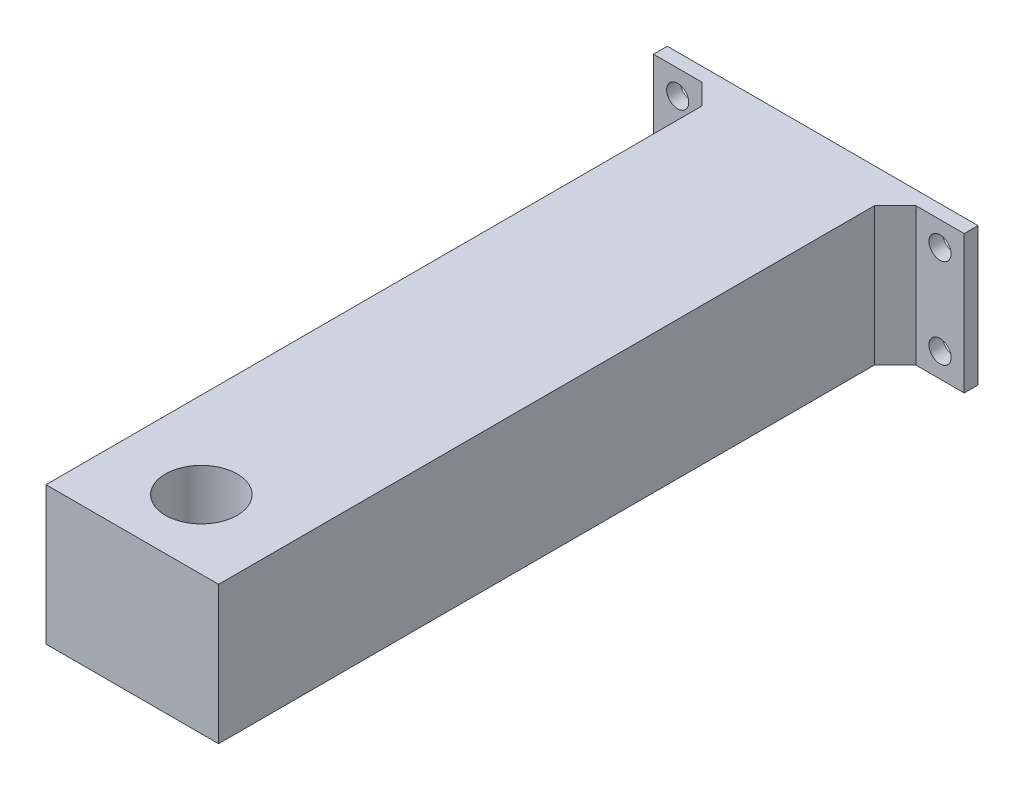
from build123d import *

# Parameters (mm, degrees)
SKETCH_1_W          = 25
SKETCH_1_H          = 20
EXTRUDE_1_DEPTH     = 100
SKETCH_2_R          = 5.2
CUT_EXTRUDE_1_DEPTH = 8
SKETCH_3_W          = 2
SKETCH_3_H          = 20
EXTRUDE_2_DEPTH     = 10
EXTRUDE_3_DEPTH     = 20
SKETCH_6_R          = 1.6
CUT_EXTRUDE_2_DEPTH = 3
SKETCH_7_W          = 2
SKETCH_7_H          = 20
EXTRUDE_4_DEPTH     = 10
EXTRUDE_5_DEPTH     = 20
SKETCH_9_R          = 1.6
CUT_EXTRUDE_3_DEPTH = 3


with BuildPart() as part:
    # ｽｹｯﾁ1 → ﾎﾞｽ - 押し出し1 (new body)
    with BuildSketch(Plane.XY):
        with Locations((-0.22894462, -4.808467742)):
            Rectangle(SKETCH_1_W, SKETCH_1_H)
    extrude(amount=EXTRUDE_1_DEPTH)

    # ｽｹｯﾁ2 → ｶｯﾄ - 押し出し1 (cut)
    with BuildSketch(Plane(origin=(0, 5.191532258, 0), x_dir=(1, 0, 0), z_dir=(0, 1, 0))):
        with Locations((-0.22894462, -90)):
            Circle(SKETCH_2_R)
    extrude(amount=-CUT_EXTRUDE_1_DEPTH, mode=Mode.SUBTRACT)

    # ｽｹｯﾁ3 → ﾎﾞｽ - 押し出し2 (add)
    with BuildSketch(Plane(origin=(12.27105538, 0, 0), x_dir=(0, 0, -1), z_dir=(1, 0, 0))):
        with Locations((-1, -4.808467742)):
            Rectangle(SKETCH_3_W, SKETCH_3_H)
    extrude(amount=EXTRUDE_2_DEPTH)

    # ｽｹｯﾁ5 → ﾎﾞｽ - 押し出し3 (add, through all)
    with BuildSketch(Plane(origin=(0, 5.191532258, 0), x_dir=(1, 0, 0), z_dir=(0, 1, 0))):
        Polygon((12.27105538, -5), (15.27105538, -2), (12.27105538, -2), align=None)
    extrude(amount=-EXTRUDE_3_DEPTH)

    # ｽｹｯﾁ6 → ｶｯﾄ - 押し出し2 (cut, through all)
    with BuildSketch(Plane.XY.offset(2)):
        with Locations((18.77105538, 1.691532258)):
            Circle(SKETCH_6_R)
        with Locations((18.77105538, -11.308467742)):
            Circle(SKETCH_6_R)
    extrude(amount=-CUT_EXTRUDE_2_DEPTH, mode=Mode.SUBTRACT)

    # ｽｹｯﾁ7 → ﾎﾞｽ - 押し出し4 (add)
    with BuildSketch(Plane.ZY.offset(12.72894462)):
        with Locations((1, -4.808467742)):
            Rectangle(SKETCH_7_W, SKETCH_7_H)
    extrude(amount=EXTRUDE_4_DEPTH)

    # ｽｹｯﾁ8 → ﾎﾞｽ - 押し出し5 (add, through all)
    with BuildSketch(Plane.XZ.offset(14.808467742)):
        Polygon((-12.72894462, 5), (-15.72894462, 2), (-12.72894462, 2), align=None)
    extrude(amount=-EXTRUDE_5_DEPTH)

    # ｽｹｯﾁ9 → ｶｯﾄ - 押し出し3 (cut, through all)
    with BuildSketch(Plane.XY.offset(2)):
        with Locations((-19.22894462, -11.308467742)):
            Circle(SKETCH_9_R)
        with Locations((-19.22894462, 1.691532258)):
            Circle(SKETCH_9_R)
    extrude(amount=-CUT_EXTRUDE_3_DEPTH, mode=Mode.SUBTRACT)


solid = part.part
